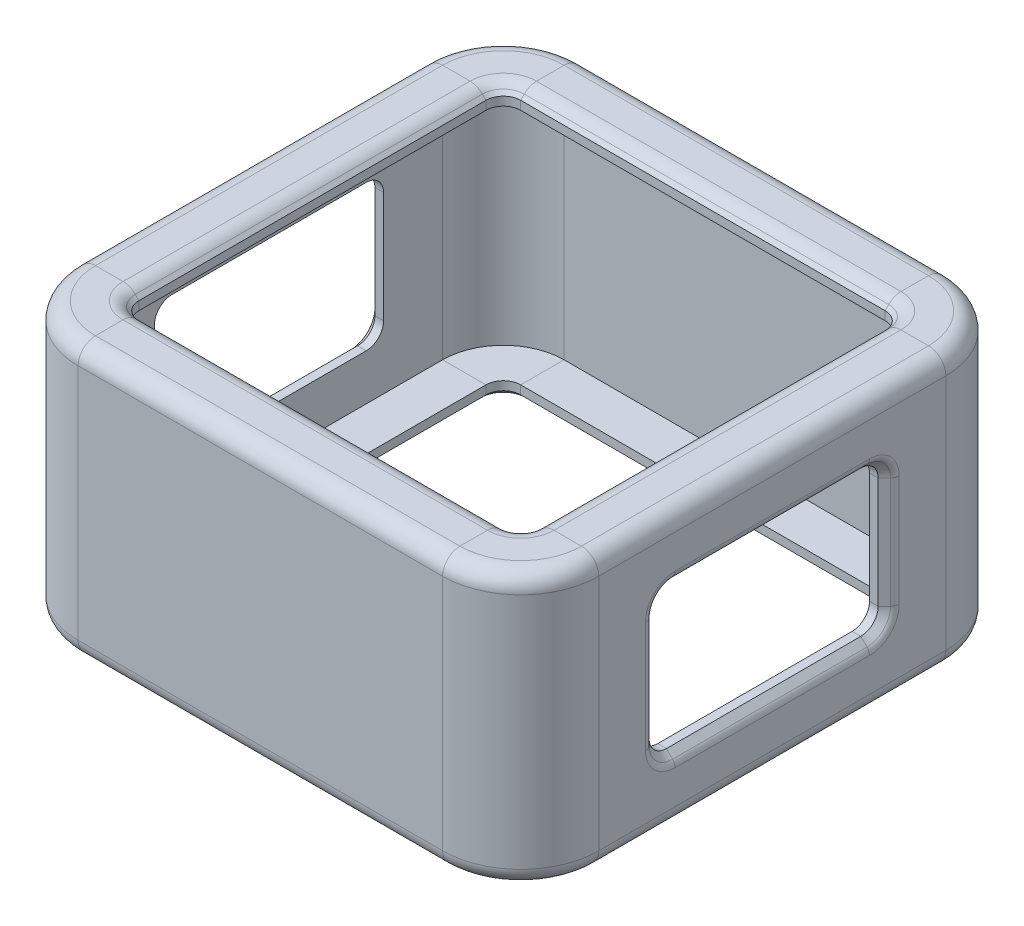
from build123d import *

# Parameters (mm, degrees)
FILLET6_TOP_FACE_R                     = 1
CUT_EXTRUDE1_SIDE_APERTURE_REACH       = 41.369
SKETCH3_W                              = 13.2
SKETCH3_H                              = 7.3
MIRROR11_COPY_1_REACH                  = 41.369
MIRROR11_COPY_1_SKETCH_W               = 13.2
MIRROR11_COPY_1_SKETCH_H               = 7.3
FILLET6_TOP_FACE_OF_MIRROR11_R         = 1
FILLET4_SIDE_APERTURE_INSIDE_CORNERS_R = 1
CHAMFER1_SIDE_APERTURE_SIZE            = 0.5
FILLET5_SIDE_APERTURE_R                = 0.5


with BuildPart() as part:
    # Sweep1: sweep along a path in Sketch2
    with BuildLine(Plane(origin=(0, 5.050213041, 0), x_dir=(1, 0, 0), z_dir=(0, 1, 0))) as sweep1_path:
        Line((1.5, 0), (1.5, 20))
        ThreePointArc((1.5, 20), (0.474873734, 22.474873734), (-2, 23.5))
        Line((-2, 23.5), (-23, 23.5))
        ThreePointArc((-23, 23.5), (-25.474873734, 22.474873734), (-26.5, 20))
        Line((-26.5, 20), (-26.5, 0))
        ThreePointArc((-26.5, 0), (-25.474873734, -2.474873734), (-23, -3.5))
        Line((-23, -3.5), (-2, -3.5))
        ThreePointArc((-2, -3.5), (0.474873734, -2.474873734), (1.5, 0))
    # Sketch1 → Sweep1 (sweep)
    with BuildSketch(Plane.XY):
        Polygon((1.5, 6.050213041), (1.5, -0.8), (2.5, -0.8), (2.5, 7.050213041), (-0.5, 7.050213041), (-1, 6.550213041), (-1, 6.050213041), align=None)
    sweep1 = sweep(path=sweep1_path.line)

    # Fillet6 (top face)
    fillet6_top_face_edges = [part.edges().sort_by_distance(p)[0] for p in [
        (-12.5, 7.050213041, -24.5),
        (-12.5, 7.050213041, -21.5),
        (-26.181980515, 7.050213041, -23.181980515),
        (-24.060660172, 7.050213041, -21.060660172),
        (-27.5, 7.050213041, -10),
        (-24.5, 7.050213041, -10),
        (-26.181980515, 7.050213041, 3.181980515),
        (-24.060660172, 7.050213041, 1.060660172),
        (-12.5, 7.050213041, 4.5),
        (-12.5, 7.050213041, 1.5),
        (1.181980515, 7.050213041, 3.181980515),
        (-0.939339828, 7.050213041, 1.060660172),
        (2.5, 7.050213041, -10),
        (-0.5, 7.050213041, -10),
        (1.181980515, 7.050213041, -23.181980515),
        (-0.939339828, 7.050213041, -21.060660172),
    ]]
    fillet(fillet6_top_face_edges, radius=FILLET6_TOP_FACE_R)

    # Sketch3 → Cut-Extrude1 (side aperture) (cut, up to next)
    with BuildSketch(Plane(origin=(2.5, 0, 0), x_dir=(0, 0, -1), z_dir=(1, 0, 0)), mode=Mode.PRIVATE) as cut_extrude1_side_aperture_sk1:
        with Locations((10, -0.249786959)):
            Rectangle(SKETCH3_W, SKETCH3_H)
    cut_extrude1_side_aperture_tool1 = extrude(cut_extrude1_side_aperture_sk1.sketch, amount=-CUT_EXTRUDE1_SIDE_APERTURE_REACH, mode=Mode.PRIVATE) & part.part
    cut_extrude1_side_aperture = cut_extrude1_side_aperture_tool1.solids().sort_by_distance((2.5, -0.249787, -10))[0]
    add(cut_extrude1_side_aperture, mode=Mode.SUBTRACT)

    # Mirror6: Cut-Extrude1 (side aperture) across plane
    add(cut_extrude1_side_aperture.mirror(Plane.ZY.offset(12.5)), mode=Mode.SUBTRACT)

    # Mirror11: Sweep1, Cut-Extrude1 (side aperture) across plane
    add(sweep1.mirror(Plane.ZX.offset(-0.8)))
    add(cut_extrude1_side_aperture.mirror(Plane.ZX.offset(-0.8)), mode=Mode.SUBTRACT)

    # Mirror11 copy 1 sketch → Mirror11 copy 1 (cut, up to next)
    with BuildSketch(Plane(origin=(-27.5, -1.6, 0), x_dir=(0, 0, -1), z_dir=(-1, 0, 0)), mode=Mode.PRIVATE) as mirror11_copy_1_sk1:
        with Locations((10, -0.249786959)):
            Rectangle(MIRROR11_COPY_1_SKETCH_W, MIRROR11_COPY_1_SKETCH_H)
    mirror11_copy_1_tool1 = extrude(mirror11_copy_1_sk1.sketch, amount=-MIRROR11_COPY_1_REACH, mode=Mode.PRIVATE) & part.part
    add(mirror11_copy_1_tool1.solids().sort_by_distance((-27.5, -1.350213, -10))[0], mode=Mode.SUBTRACT)

    # Fillet6 (top face) of Mirror11
    fillet6_top_face_of_mirror11_edges = [part.edges().sort_by_distance(p)[0] for p in [
        (-12.5, -8.650213041, -24.5),
        (-12.5, -8.650213041, -21.5),
        (-26.181980515, -8.650213041, -23.181980515),
        (-24.060660172, -8.650213041, -21.060660172),
        (-27.5, -8.650213041, -10),
        (-24.5, -8.650213041, -10),
        (-26.181980515, -8.650213041, 3.181980515),
        (-24.060660172, -8.650213041, 1.060660172),
        (-12.5, -8.650213041, 4.5),
        (-12.5, -8.650213041, 1.5),
        (1.181980515, -8.650213041, 3.181980515),
        (-0.939339828, -8.650213041, 1.060660172),
        (2.5, -8.650213041, -10),
        (-0.5, -8.650213041, -10),
        (1.181980515, -8.650213041, -23.181980515),
        (-0.939339828, -8.650213041, -21.060660172),
    ]]
    fillet(fillet6_top_face_of_mirror11_edges, radius=FILLET6_TOP_FACE_OF_MIRROR11_R)

    # Fillet4 (side aperture inside corners)
    fillet4_side_aperture_inside_corners_edges = [part.edges().sort_by_distance(p)[0] for p in [
        (2, 3.400213041, -16.6),
        (2, 3.400213041, -3.4),
        (-27, 3.400213041, -16.6),
        (-27, 3.400213041, -3.4),
        (2, -5.000213041, -3.4),
        (2, -5.000213041, -16.6),
        (-27, -5.000213041, -3.4),
        (-27, -5.000213041, -16.6),
    ]]
    fillet(fillet4_side_aperture_inside_corners_edges, radius=FILLET4_SIDE_APERTURE_INSIDE_CORNERS_R)

    # Chamfer1 (side aperture)
    chamfer1_side_aperture_edges = [part.edges().sort_by_distance(p)[0] for p in [
        (-27.5, -0.8, -16.6),
        (-27.5, 3.400213041, -10),
        (-27.5, -5.000213041, -10),
        (-27.5, -0.8, -3.4),
        (2.5, -5.000213041, -10),
        (2.5, -0.8, -3.4),
        (2.5, -0.8, -16.6),
        (2.5, 3.400213041, -10),
        (-27.5, 3.107319822, -16.307106781),
        (-27.5, -4.707319822, -16.307106781),
        (-27.5, 3.107319822, -3.692893219),
        (-27.5, -4.707319822, -3.692893219),
        (2.5, -4.707319822, -3.692893219),
        (2.5, -4.707319822, -16.307106781),
        (2.5, 3.107319822, -3.692893219),
        (2.5, 3.107319822, -16.307106781),
    ]]
    chamfer(chamfer1_side_aperture_edges, length=CHAMFER1_SIDE_APERTURE_SIZE)

    # Fillet5 (side aperture)
    fillet5_side_aperture_edges = [part.edges().sort_by_distance(p)[0] for p in [
        (-27.5, -0.8, -17.1),
        (-27.5, 3.460873213, -16.660660172),
        (-27.5, -5.060873213, -16.660660172),
        (-27.5, 3.900213041, -10),
        (-27.5, -5.500213041, -10),
        (-27.5, 3.460873213, -3.339339828),
        (-27.5, -5.060873213, -3.339339828),
        (-27.5, -0.8, -2.9),
        (2.5, -0.8, -2.9),
        (2.5, 3.460873213, -3.339339828),
        (2.5, 3.900213041, -10),
        (2.5, 3.460873213, -16.660660172),
        (2.5, -0.8, -17.1),
        (2.5, -5.060873213, -3.339339828),
        (2.5, -5.060873213, -16.660660172),
        (2.5, -5.500213041, -10),
    ]]
    fillet(fillet5_side_aperture_edges, radius=FILLET5_SIDE_APERTURE_R)


solid = part.part
